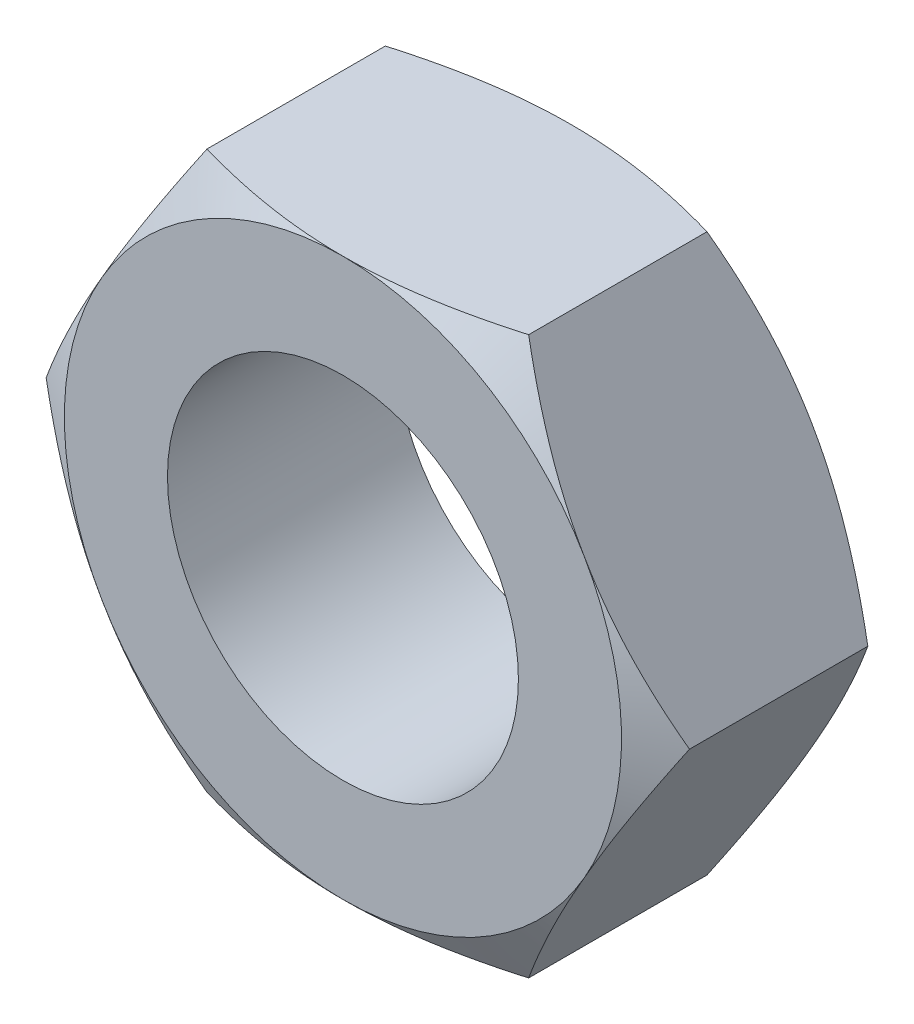
from build123d import *

# Parameters (mm, degrees)
SKETCH1_R           = 4
BOSS_EXTRUDE1_DEPTH = 5.2
SKETCH2_OUTSIDE_W   = 38.002
SKETCH2_OUTSIDE_H   = 36.038
SKETCH2_OUTSIDE_R   = 6.35
CUT_EXTRUDE1_DEPTH  = 5
CUT_EXTRUDE1_DRAFT  = -60
SKETCH3_OUTSIDE_W   = 38.002
SKETCH3_OUTSIDE_H   = 36.038
SKETCH3_OUTSIDE_R   = 6.35
CUT_EXTRUDE2_DEPTH  = 5
CUT_EXTRUDE2_DRAFT  = -60


with BuildPart() as part:
    # Sketch1 → Boss-Extrude1 (new body)
    with BuildSketch(Plane.XY):
        Polygon((7.332348419, 0), (3.666174209, 6.35), (-3.666174209, 6.35), (-7.332348419, 0), (-3.666174209, -6.35), (3.666174209, -6.35), align=None)
        Circle(SKETCH1_R, mode=Mode.SUBTRACT)
    extrude(amount=BOSS_EXTRUDE1_DEPTH)


with BuildPart() as cut_extrude1_tool:
    # Sketch2 outside → Cut-Extrude1 (with draft: the straight prism first)
    with BuildSketch(Plane.XY.offset(5.2)):
        Rectangle(SKETCH2_OUTSIDE_W, SKETCH2_OUTSIDE_H)
        Circle(SKETCH2_OUTSIDE_R, mode=Mode.SUBTRACT)
    extrude(amount=-CUT_EXTRUDE1_DEPTH)
    # Cut-Extrude1: the draft: its side faces are tilted about the plane it starts from
    cut_extrude1_sides = [cut_extrude1_tool.faces().sort_by_distance(p)[0] for p in [
        (0, -18.019, 2.7),
        (19.001, 0, 2.7),
        (0, 18.019, 2.7),
        (-19.001, 0, 2.7),
        (-6.35, 0, 2.7),
    ]]
    draft(cut_extrude1_sides, Plane.XY.offset(5.2), CUT_EXTRUDE1_DRAFT)


with BuildPart() as part_1:
    add(part.part)

    # Cut-Extrude1: cut by cut_extrude1_tool
    add(cut_extrude1_tool.part, mode=Mode.SUBTRACT)


with BuildPart() as cut_extrude2_tool:
    # Sketch3 outside → Cut-Extrude2 (with draft: the straight prism first)
    with BuildSketch(Plane(origin=(0, 0, 0), x_dir=(-1, 0, 0), z_dir=(0, 0, -1))):
        Rectangle(SKETCH3_OUTSIDE_W, SKETCH3_OUTSIDE_H)
        Circle(SKETCH3_OUTSIDE_R, mode=Mode.SUBTRACT)
    extrude(amount=-CUT_EXTRUDE2_DEPTH)
    # Cut-Extrude2: the draft: its side faces are tilted about the plane it starts from
    cut_extrude2_sides = [cut_extrude2_tool.faces().sort_by_distance(p)[0] for p in [
        (0, -18.019, 2.5),
        (-19.001, 0, 2.5),
        (0, 18.019, 2.5),
        (19.001, 0, 2.5),
        (6.35, 0, 2.5),
    ]]
    draft(cut_extrude2_sides, Plane(origin=(0, 0, 0), x_dir=(-1, 0, 0), z_dir=(0, 0, -1)), CUT_EXTRUDE2_DRAFT)


with BuildPart() as part_2:
    add(part_1.part)

    # Cut-Extrude2: cut by cut_extrude2_tool
    add(cut_extrude2_tool.part, mode=Mode.SUBTRACT)


solid = part_2.part
